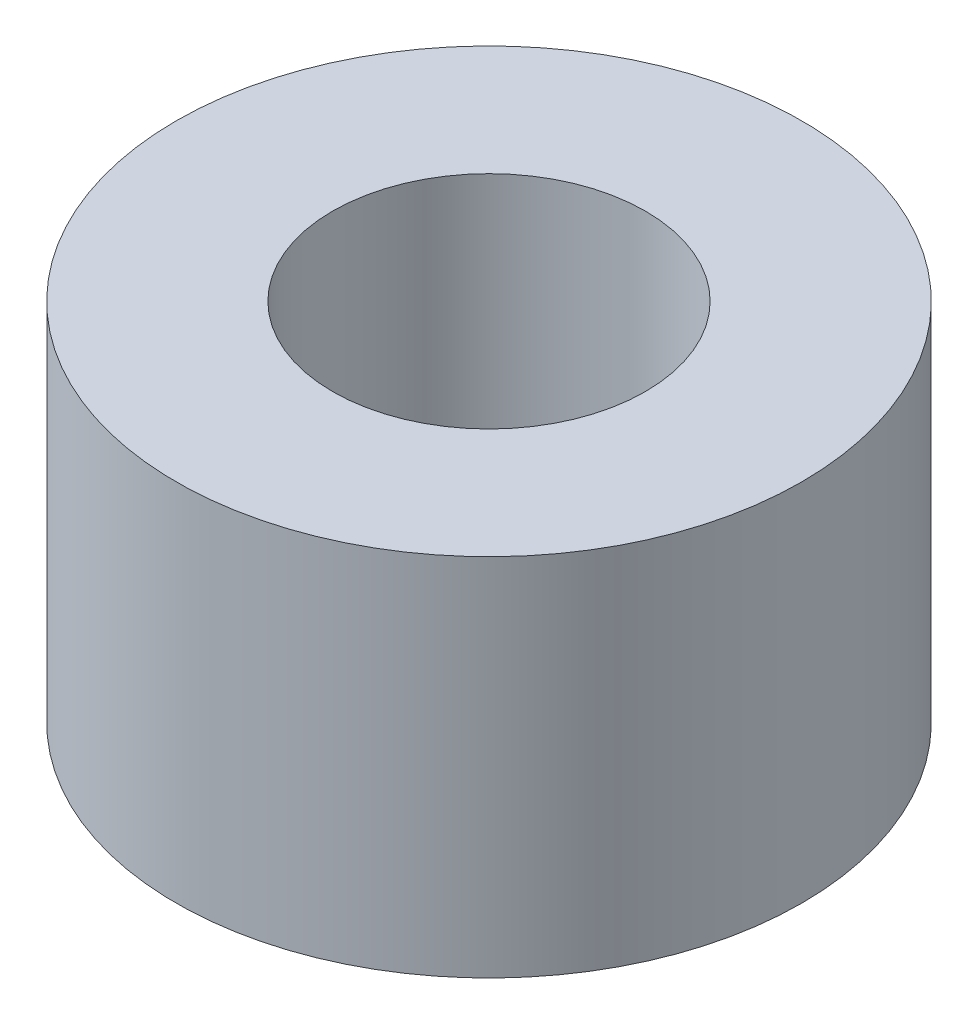
from build123d import *

# Parameters (mm, degrees)
SKETCH1_R           = 60
SKETCH1_R_2         = 30
EXTRUDE_THIN1_DEPTH = 70


with BuildPart() as part:
    # Sketch1 → Extrude-Thin1 (new body)
    with BuildSketch(Plane(origin=(0, 0, 0), x_dir=(1, 0, 0), z_dir=(0, 1, 0))):
        Circle(SKETCH1_R)
        Circle(SKETCH1_R_2, mode=Mode.SUBTRACT)
    extrude(amount=EXTRUDE_THIN1_DEPTH)


solid = part.part
